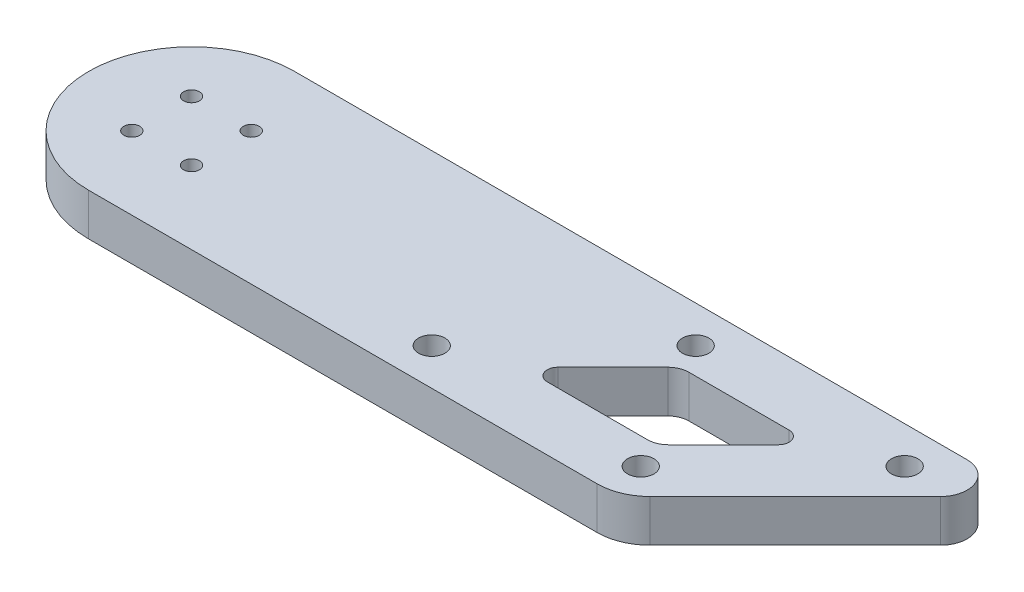
from build123d import *

# Parameters (mm, degrees)
SKETCH_1_R               = 1.5
EXTRUDE_1_DEPTH          = 8
CUT_EXTRUDE_1_DEPTH      = 1
CUT_EXTRUDE_1_DEPTH_BACK = 9
SKETCH_3_R               = 2.5
CUT_EXTRUDE_2_DEPTH      = 1
CUT_EXTRUDE_2_DEPTH_BACK = 9


with BuildPart() as part:
    # 草图1 → 凸台-拉伸1 (new body)
    with BuildSketch(Plane(origin=(0, 0, 0), x_dir=(1, 0, 0), z_dir=(0, 1, 0))):
        with BuildLine():
            Line((0, 19.5), (127.428932188, 19.5))
            ThreePointArc((127.428932188, 19.5), (132.048329851, 16.413417162), (130.964466094, 10.964466094))
            Line((130.964466094, 10.964466094), (103.428932188, -16.571067812))
            ThreePointArc((103.428932188, -16.571067812), (100.1846987, -18.738795325), (96.357864376, -19.5))
            Line((96.357864376, -19.5), (0, -19.5))
            ThreePointArc((0, -19.5), (-19.5, 0), (0, 19.5))
        make_face()
        with Locations((-5.656854249, 5.656854249)):
            Circle(SKETCH_1_R, mode=Mode.SUBTRACT)
        with Locations((5.656854249, 5.656854249)):
            Circle(SKETCH_1_R, mode=Mode.SUBTRACT)
        with Locations((5.656854249, -5.656854249)):
            Circle(SKETCH_1_R, mode=Mode.SUBTRACT)
        with Locations((-5.656854249, -5.656854249)):
            Circle(SKETCH_1_R, mode=Mode.SUBTRACT)
    extrude(amount=EXTRUDE_1_DEPTH)

    # 草图2 → 切除-拉伸1 (cut, two sides)
    with BuildSketch(Plane(origin=(0, 8, 0), x_dir=(1, 0, 0), z_dir=(0, 1, 0))) as cut_extrude_1_sk:
        with BuildLine():
            Line((73.487806691, -4.085786438), (83.902020254, 6.328427125))
            ThreePointArc((83.902020254, 6.328427125), (85.199713649, 7.19551813), (86.730447378, 7.5))
            Line((86.730447378, 7.5), (105.701010127, 7.5))
            ThreePointArc((105.701010127, 7.5), (107.548769192, 6.265366865), (107.115223689, 4.085786438))
            Line((107.115223689, 4.085786438), (96.701010127, -6.328427125))
            ThreePointArc((96.701010127, -6.328427125), (95.403316732, -7.19551813), (93.872583002, -7.5))
            Line((93.872583002, -7.5), (74.902020254, -7.5))
            ThreePointArc((74.902020254, -7.5), (73.054261189, -6.265366865), (73.487806691, -4.085786438))
        make_face()
    extrude(amount=CUT_EXTRUDE_1_DEPTH, mode=Mode.SUBTRACT)
    extrude(cut_extrude_1_sk.sketch, amount=-CUT_EXTRUDE_1_DEPTH_BACK, mode=Mode.SUBTRACT)

    # 草图3 → 切除-拉伸2 (cut, two sides)
    with BuildSketch(Plane(origin=(0, 8, 0), x_dir=(1, 0, 0), z_dir=(0, 1, 0))) as cut_extrude_2_sk:
        with Locations((58.002525317, -12.5)):
            Circle(SKETCH_3_R)
        with Locations((83.002525317, 12.5)):
            Circle(SKETCH_3_R)
        with Locations((97.600505063, -12.5)):
            Circle(SKETCH_3_R)
        with Locations((122.600505063, 12.5)):
            Circle(SKETCH_3_R)
    extrude(amount=CUT_EXTRUDE_2_DEPTH, mode=Mode.SUBTRACT)
    extrude(cut_extrude_2_sk.sketch, amount=-CUT_EXTRUDE_2_DEPTH_BACK, mode=Mode.SUBTRACT)


solid = part.part
